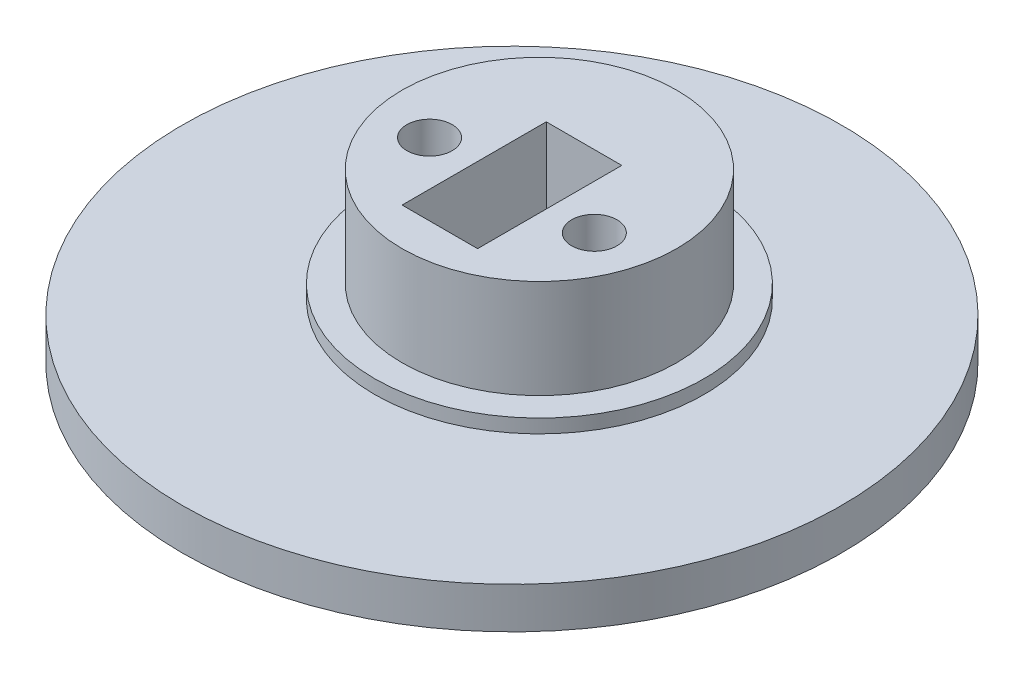
from build123d import *

# Parameters (mm, degrees)
SKETCH1_R           = 24
SKETCH1_R_2         = 1.65
SKETCH1_W           = 5.5
SKETCH1_H           = 10.5
BOSS_EXTRUDE1_DEPTH = 3
SKETCH2_R           = 12
SKETCH2_R_2         = 1.65
SKETCH2_W           = 5.5
SKETCH2_H           = 10.5
BOSS_EXTRUDE2_DEPTH = 1
SKETCH4_R           = 10
SKETCH4_R_2         = 1.65
SKETCH4_W           = 5.5
SKETCH4_H           = 10.5
BOSS_EXTRUDE3_DEPTH = 7.2


with BuildPart() as part:
    # Sketch1 → Boss-Extrude1 (new body)
    with BuildSketch(Plane(origin=(0, 0, 0), x_dir=(1, 0, 0), z_dir=(0, 1, 0))):
        Circle(SKETCH1_R)
        with Locations((-6, 0)):
            Circle(SKETCH1_R_2, mode=Mode.SUBTRACT)
        with Locations((6, 0)):
            Circle(SKETCH1_R_2, mode=Mode.SUBTRACT)
        Rectangle(SKETCH1_W, SKETCH1_H, mode=Mode.SUBTRACT)
    extrude(amount=BOSS_EXTRUDE1_DEPTH)

    # Sketch2 → Boss-Extrude2 (add)
    with BuildSketch(Plane(origin=(0, 3, 0), x_dir=(1, 0, 0), z_dir=(0, 1, 0))):
        with Locations((0, 2)):
            Circle(SKETCH2_R)
        with Locations((-6, 0)):
            Circle(SKETCH2_R_2, mode=Mode.SUBTRACT)
        with Locations((6, 0)):
            Circle(SKETCH2_R_2, mode=Mode.SUBTRACT)
        Rectangle(SKETCH2_W, SKETCH2_H, mode=Mode.SUBTRACT)
    extrude(amount=BOSS_EXTRUDE2_DEPTH)

    # Sketch4 → Boss-Extrude3 (add)
    with BuildSketch(Plane(origin=(0, 4, 0), x_dir=(1, 0, 0), z_dir=(0, 1, 0))):
        with Locations((0, 2)):
            Circle(SKETCH4_R)
        with Locations((-6, 0)):
            Circle(SKETCH4_R_2, mode=Mode.SUBTRACT)
        with Locations((6, 0)):
            Circle(SKETCH4_R_2, mode=Mode.SUBTRACT)
        Rectangle(SKETCH4_W, SKETCH4_H, mode=Mode.SUBTRACT)
    extrude(amount=BOSS_EXTRUDE3_DEPTH)


solid = part.part
